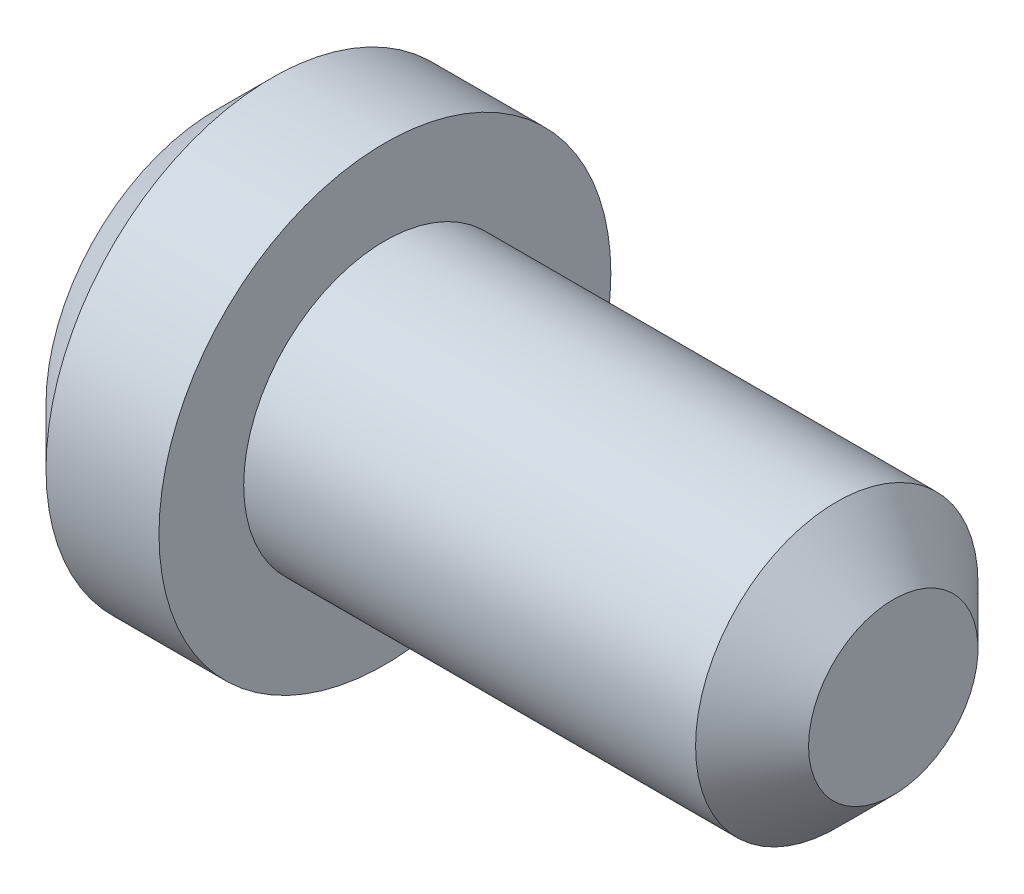
from build123d import *


with BuildPart() as part:
    # Sketch1 → Revolve1 (revolve)
    with BuildSketch(Plane.XY):
        Polygon((0, 40), (20, 40), (20, 25), (100, 25), (110, 15), (110, 0), (-10, 0), (-10, 30), align=None)
    revolve(axis=Axis((-10, 0, 0), (1, 0, 0)))


solid = part.part
